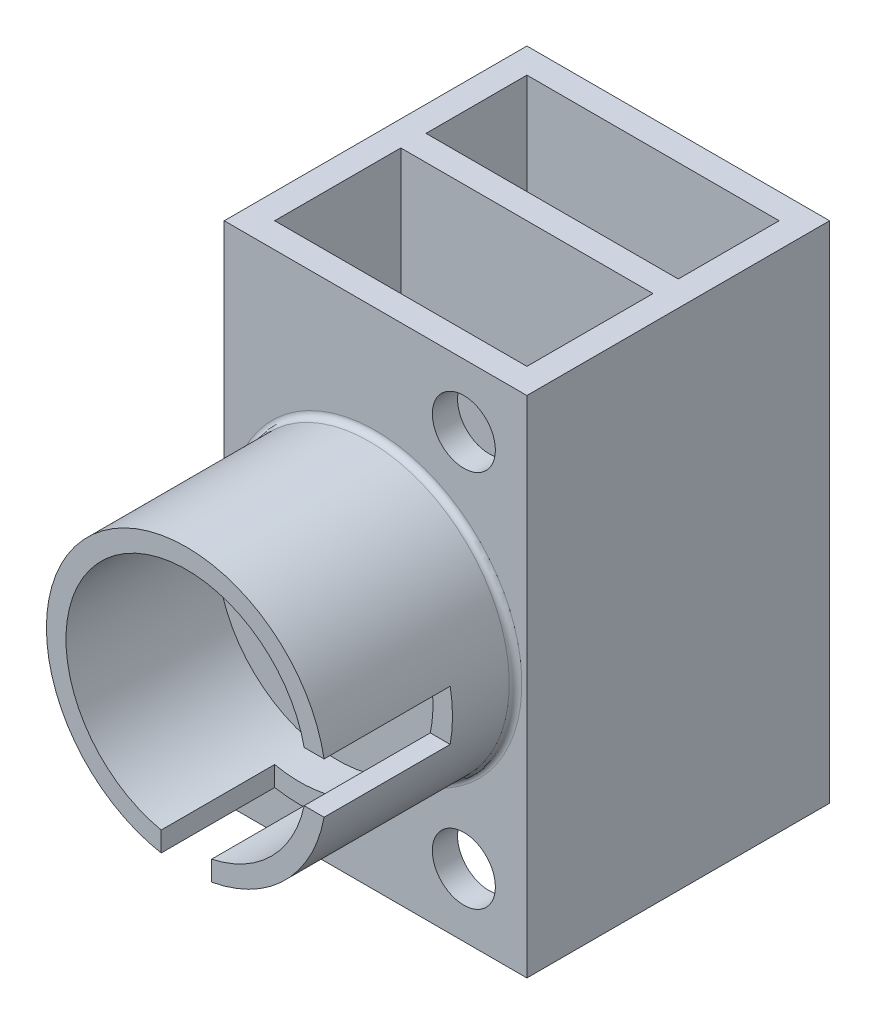
from build123d import *

# Parameters (mm, degrees)
SKETCH1_W           = 24
SKETCH1_H           = 24
BOSS_EXTRUDE1_DEPTH = 40
SHELL3_T            = -2
SKETCH3_R           = 11.1
BOSS_EXTRUDE3_DEPTH = 15
SKETCH4_R           = 9.55
CUT_EXTRUDE3_DEPTH  = 12
FILLET4_R           = 0.5
SKETCH2_W           = 20
SKETCH2_H           = 2
BOSS_EXTRUDE5_DEPTH = 40
SKETCH6_W           = 20
SKETCH6_H           = 4
CUT_EXTRUDE4_DEPTH  = 8
SKETCH7_W           = 4
SKETCH7_H           = 18
CUT_EXTRUDE5_DEPTH  = 8
SKETCH8_R           = 2.5
CUT_EXTRUDE6_DEPTH  = 2


with BuildPart() as part:
    # Sketch1 → Boss-Extrude1 (new body)
    with BuildSketch(Plane(origin=(0, 0, 0), x_dir=(1, 0, 0), z_dir=(0, 1, 0))):
        Rectangle(SKETCH1_W, SKETCH1_H)
    extrude(amount=BOSS_EXTRUDE1_DEPTH)

    # Shell3
    shell3_openings = [part.faces().sort_by_distance(p)[0] for p in [
        (0, 40, 0),
        (0, 0, 0),
    ]]
    offset(amount=SHELL3_T, openings=shell3_openings, kind=Kind.INTERSECTION)

    # Sketch3 → Boss-Extrude3 (add)
    with BuildSketch(Plane.XY.offset(12)):
        with Locations((0, 20)):
            Circle(SKETCH3_R)
    extrude(amount=BOSS_EXTRUDE3_DEPTH)

    # Sketch4 → Cut-Extrude3 (cut)
    with BuildSketch(Plane.XY.offset(27)):
        with Locations((0, 20)):
            Circle(SKETCH4_R)
    extrude(amount=-CUT_EXTRUDE3_DEPTH, mode=Mode.SUBTRACT)

    # Fillet4
    fillet4_edges = [part.edges().sort_by_distance(p)[0] for p in [
        (-11.1, 20, 12),
    ]]
    fillet(fillet4_edges, radius=FILLET4_R)

    # Sketch2 → Boss-Extrude5 (add)
    with BuildSketch(Plane(origin=(0, 40, 0), x_dir=(1, 0, 0), z_dir=(0, 1, 0))):
        with Locations((0, 1)):
            Rectangle(SKETCH2_W, SKETCH2_H)
    extrude(amount=-BOSS_EXTRUDE5_DEPTH)

    # Sketch6 → Cut-Extrude4 (cut)
    with BuildSketch(Plane(origin=(11.1, 0, 0), x_dir=(0, 0, -1), z_dir=(1, 0, 0))):
        with Locations((-27, 20)):
            Rectangle(SKETCH6_W, SKETCH6_H)
    extrude(amount=-CUT_EXTRUDE4_DEPTH, mode=Mode.SUBTRACT)

    # Sketch7 → Cut-Extrude5 (cut)
    with BuildSketch(Plane(origin=(0, 8.9, 0), x_dir=(1, 0, 0), z_dir=(0, 1, 0))):
        with Locations((0, -27)):
            Rectangle(SKETCH7_W, SKETCH7_H)
    extrude(amount=CUT_EXTRUDE5_DEPTH, mode=Mode.SUBTRACT)

    # Sketch8 → Cut-Extrude6 (cut)
    with BuildSketch(Plane.XY.offset(12)):
        with Locations((7, 35)):
            Circle(SKETCH8_R)
    cut_extrude6 = extrude(amount=-CUT_EXTRUDE6_DEPTH, mode=Mode.SUBTRACT)

    # Mirror1: Cut-Extrude6 across plane
    add(cut_extrude6.mirror(Plane.ZX.offset(20)), mode=Mode.SUBTRACT)


solid = part.part
